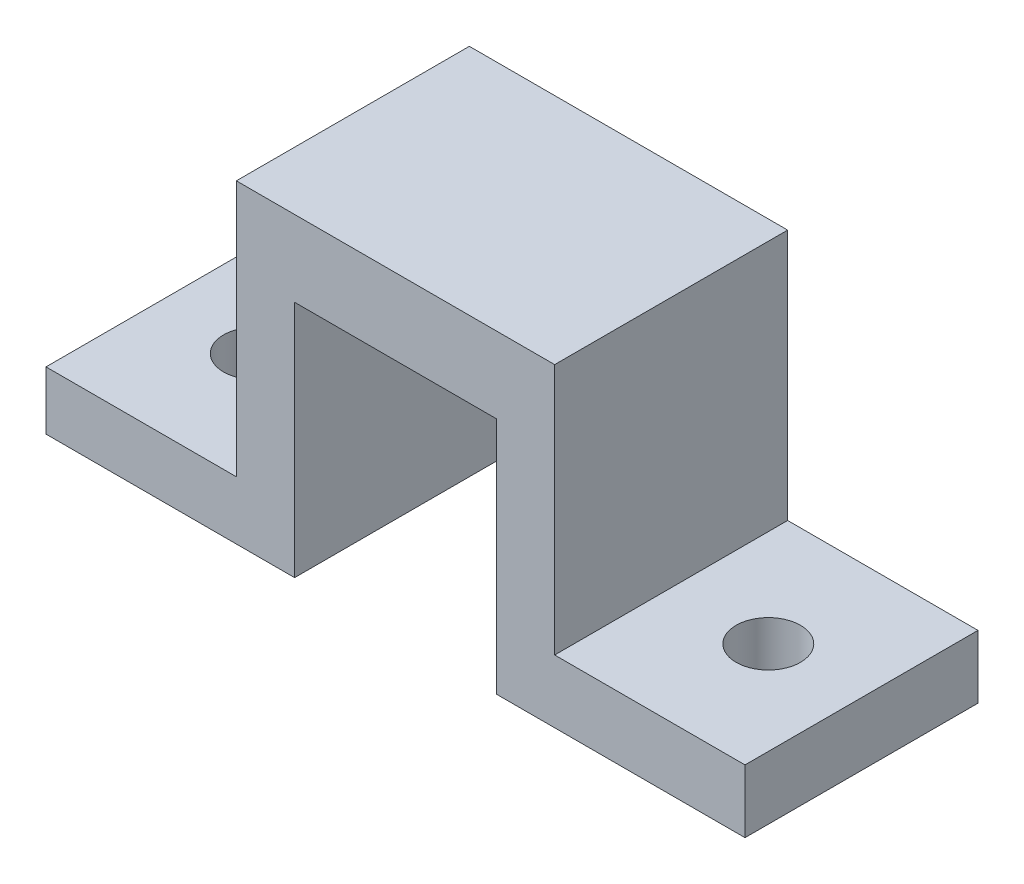
from build123d import *

# Parameters (mm, degrees)
BOSS_EXTRUDE1_DEPTH = 12.7
SKETCH2_R           = 1.7526
CUT_EXTRUDE3_DEPTH  = 4.175
SKETCH3_R           = 1.7526
CUT_EXTRUDE4_DEPTH  = 4.436950898


with BuildPart() as part:
    # Sketch1 → Boss-Extrude1 (new body)
    with BuildSketch(Plane.XY):
        Polygon((-5.5, -6.5), (-19.05, -6.5), (-19.05, -3.325), (-8.675, -3.325), (-8.675, 10.645), (8.675, 10.645), (8.675, -3.063049102), (19.05, -3.063049102), (19.05, -6.5), (5.5, -6.5), (5.5, 6.5), (-5.5, 6.5), align=None)
    extrude(amount=BOSS_EXTRUDE1_DEPTH)

    # Sketch2 → Cut-Extrude3 (cut, through all)
    with BuildSketch(Plane(origin=(0, -3.325, 0), x_dir=(1, 0, 0), z_dir=(0, 1, 0))):
        with Locations((-13.97, -6.35)):
            Circle(SKETCH2_R)
    extrude(amount=-CUT_EXTRUDE3_DEPTH, mode=Mode.SUBTRACT)

    # Sketch3 → Cut-Extrude4 (cut, through all)
    with BuildSketch(Plane(origin=(0, -3.063049102, 0), x_dir=(1, 0, 0), z_dir=(0, 1, 0))):
        with Locations((13.97, -6.35)):
            Circle(SKETCH3_R)
    extrude(amount=-CUT_EXTRUDE4_DEPTH, mode=Mode.SUBTRACT)


solid = part.part
